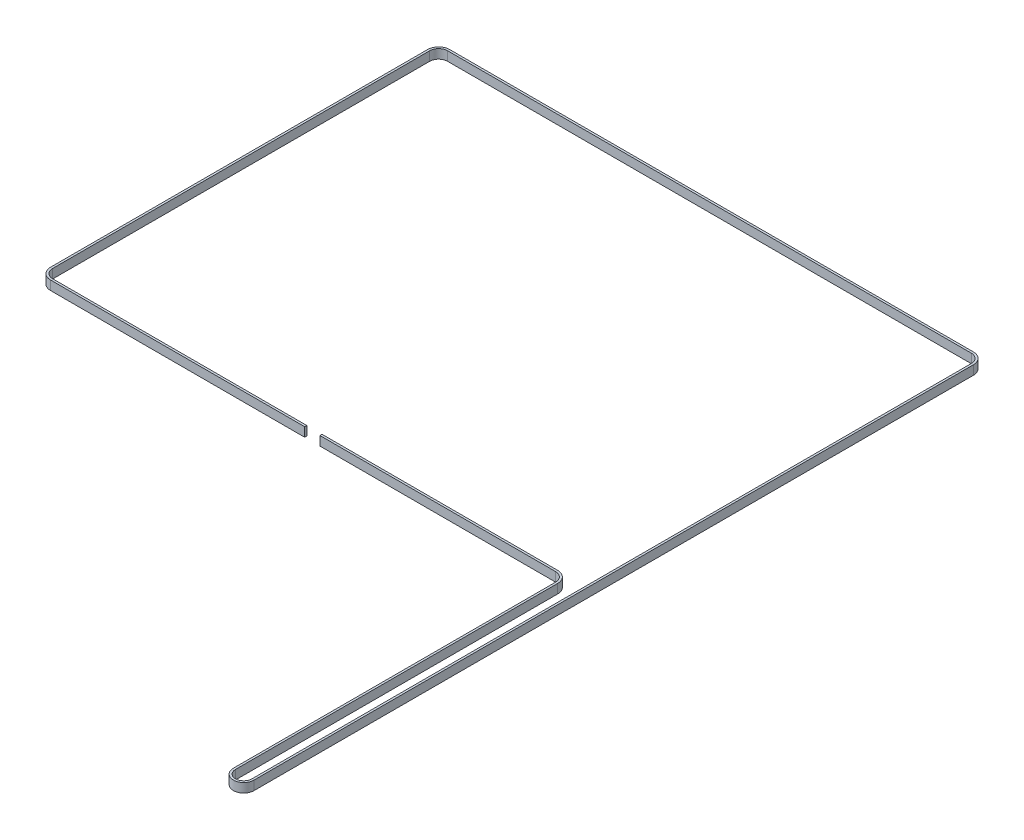
from build123d import *

# Parameters (mm, degrees)
EXTRUDE_THIN1_DEPTH = 6


with BuildPart() as part:
    # Sketch1 → Extrude-Thin1 (new body)
    with BuildSketch(Plane(origin=(0, 0, 0), x_dir=(1, 0, 0), z_dir=(0, 1, 0))):
        with BuildLine():
            Line((173.28, -259.643481844), (6.875, -259.643481844))
            ThreePointArc((6.875, -259.643481844), (2.723576088, -257.923905757), (1.004, -253.772481844))
            Line((1.004, -253.772481844), (1.004, -6.875))
            ThreePointArc((1.004, -6.875), (2.723576088, -2.723576088), (6.875, -1.004))
            Line((6.875, -1.004), (349.875, -1.004))
            ThreePointArc((349.875, -1.004), (354.026423912, -2.723576088), (355.746, -6.875))
            Line((355.746, -6.875), (355.746, -478.035))
            ThreePointArc((355.746, -478.035), (350.38, -483.401), (345.014, -478.035))
            Line((345.014, -478.035), (345.014, -267.017481844))
            ThreePointArc((345.014, -267.017481844), (342.854205404, -261.80327644), (337.64, -259.643481844))
            Line((337.64, -259.643481844), (183.275, -259.643481844))
            Line((183.275, -259.643481844), (183.275, -261.023481844))
            Line((183.275, -261.023481844), (337.64, -261.023481844))
            ThreePointArc((337.64, -261.023481844), (341.878398046, -262.779083798), (343.634, -267.017481844))
            Line((343.634, -267.017481844), (343.634, -478.035))
            ThreePointArc((343.634, -478.035), (350.38, -484.781), (357.126, -478.035))
            Line((357.126, -478.035), (357.126, -6.875))
            ThreePointArc((357.126, -6.875), (355.00223127, -1.74776873), (349.875, 0.376))
            Line((349.875, 0.376), (6.875, 0.376))
            ThreePointArc((6.875, 0.376), (1.74776873, -1.74776873), (-0.376, -6.875))
            Line((-0.376, -6.875), (-0.376, -253.772481844))
            ThreePointArc((-0.376, -253.772481844), (1.74776873, -258.899713115), (6.875, -261.023481844))
            Line((6.875, -261.023481844), (173.28, -261.023481844))
            Line((173.28, -261.023481844), (173.28, -259.643481844))
        make_face()
    extrude(amount=EXTRUDE_THIN1_DEPTH)


solid = part.part
